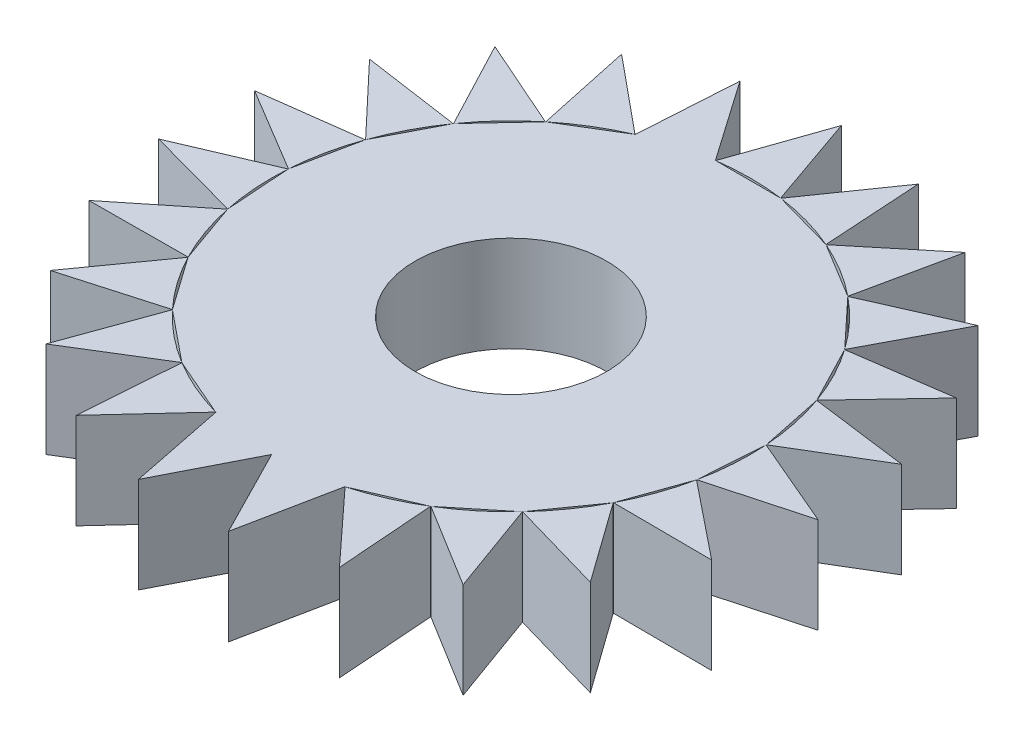
from build123d import *

# Parameters (mm, degrees)
BOSS_EXTRUDE1_DEPTH    = 2
SKETCH1_R              = 2
BOSS_EXTRUDE1_2_DEPTH  = 2
BOSS_EXTRUDE1_3_DEPTH  = 2
BOSS_EXTRUDE1_4_DEPTH  = 2
BOSS_EXTRUDE1_5_DEPTH  = 2
BOSS_EXTRUDE1_6_DEPTH  = 2
BOSS_EXTRUDE1_7_DEPTH  = 2
BOSS_EXTRUDE1_8_DEPTH  = 2
BOSS_EXTRUDE1_9_DEPTH  = 2
BOSS_EXTRUDE1_10_DEPTH = 2
BOSS_EXTRUDE1_11_DEPTH = 2
BOSS_EXTRUDE1_12_DEPTH = 2
BOSS_EXTRUDE1_13_DEPTH = 2
BOSS_EXTRUDE1_14_DEPTH = 2
BOSS_EXTRUDE1_15_DEPTH = 2
BOSS_EXTRUDE1_16_DEPTH = 2
BOSS_EXTRUDE1_17_DEPTH = 2
BOSS_EXTRUDE1_18_DEPTH = 2
BOSS_EXTRUDE1_19_DEPTH = 2
BOSS_EXTRUDE1_20_DEPTH = 2
BOSS_EXTRUDE1_21_DEPTH = 2


with BuildPart() as part:
    # Sketch1 → Boss-Extrude1 (new body)
    with BuildSketch(Plane(origin=(0, 0, 0), x_dir=(1, 0, 0), z_dir=(0, 1, 0))):
        with BuildLine():
            ThreePointArc((-0.678341052, 4.953771636), (0, 5), (0.678341052, 4.953771636))
            Line((0.678341052, 4.953771636), (0, 6.900057726))
            Line((0, 6.900057726), (-0.678341052, 4.953771636))
        make_face()
    extrude(amount=BOSS_EXTRUDE1_DEPTH)


with BuildPart() as body_2:
    # Sketch1 → Boss-Extrude1 2 (new body)
    with BuildSketch(Plane(origin=(0, 0, 0), x_dir=(1, 0, 0), z_dir=(0, 1, 0))):
        with BuildLine():
            ThreePointArc((0.683325267, 4.953086571), (0.680833245, 4.95342973), (0.678341052, 4.953771636))
            Line((0.678341052, 4.953771636), (-0.678341052, 4.953771636))
            ThreePointArc((-0.678341052, 4.953771636), (-0.680833245, 4.95342973), (-0.683325267, 4.953086571))
            Line((-0.683325267, 4.953086571), (-1.861613295, 6.644184868))
            Line((-1.861613295, 6.644184868), (-1.989697918, 4.58705812))
            ThreePointArc((-1.989697918, 4.58705812), (-1.992005449, 4.586056508), (-1.994312476, 4.585053734))
            Line((-1.994312476, 4.585053734), (-3.153487992, 3.880143488))
            ThreePointArc((-3.153487992, 3.880143488), (-3.155439722, 3.878556454), (-3.157390653, 3.876968437))
            Line((-3.157390653, 3.876968437), (-4.083398287, 2.885456364))
            ThreePointArc((-4.083398287, 2.885456364), (-4.084849465, 2.883401611), (-4.086299609, 2.881346127))
            Line((-4.086299609, 2.881346127), (-4.710461612, 1.676768141))
            ThreePointArc((-4.710461612, 1.676768141), (-4.711304611, 1.674398061), (-4.712146416, 1.672027556))
            Line((-4.712146416, 1.672027556), (-4.988171548, 0.343721697))
            ThreePointArc((-4.988171548, 0.343721697), (-4.988343846, 0.341212067), (-4.988514881, 0.338702351))
            Line((-4.988514881, 0.338702351), (-4.89593162, -1.014817014))
            ThreePointArc((-4.89593162, -1.014817014), (-4.895420438, -1.017280065), (-4.894908018, -1.019742859))
            Line((-4.894908018, -1.019742859), (-4.440582841, -2.298091389))
            ThreePointArc((-4.440582841, -2.298091389), (-4.439426092, -2.300325189), (-4.438268219, -2.302558406))
            Line((-4.438268219, -2.302558406), (-3.655896347, -3.410926839))
            ThreePointArc((-3.655896347, -3.410926839), (-3.654179821, -3.412765716), (-3.652462371, -3.414603729))
            Line((-3.652462371, -3.414603729), (-2.600068745, -4.270789449))
            ThreePointArc((-2.600068745, -4.270789449), (-2.59791975, -4.272097023), (-2.595770098, -4.273403515))
            Line((-2.595770098, -4.273403515), (-1.351405939, -4.813907144))
            ThreePointArc((-1.351405939, -4.813907144), (-1.348983856, -4.814586437), (-1.346561431, -4.815264511))
            Line((-1.346561431, -4.815264511), (-0.939557739, -6.835790216))
            Line((-0.939557739, -6.835790216), (-0.002515537, -4.999999367))
            ThreePointArc((-0.002515537, -4.999999367), (0, -5), (0.002515537, -4.999999367))
            Line((0.002515537, -4.999999367), (0.939557739, -6.835790216))
            Line((0.939557739, -6.835790216), (1.346561431, -4.815264511))
            ThreePointArc((1.346561431, -4.815264511), (1.348983856, -4.814586437), (1.351405939, -4.813907144))
            Line((1.351405939, -4.813907144), (2.595770098, -4.273403515))
            ThreePointArc((2.595770098, -4.273403515), (2.59791975, -4.272097023), (2.600068745, -4.270789449))
            Line((2.600068745, -4.270789449), (3.652462371, -3.414603729))
            ThreePointArc((3.652462371, -3.414603729), (3.654179821, -3.412765716), (3.655896347, -3.410926839))
            Line((3.655896347, -3.410926839), (4.438268219, -2.302558406))
            ThreePointArc((4.438268219, -2.302558406), (4.439426092, -2.300325189), (4.440582841, -2.298091389))
            Line((4.440582841, -2.298091389), (4.894908018, -1.019742859))
            ThreePointArc((4.894908018, -1.019742859), (4.895420438, -1.017280065), (4.89593162, -1.014817014))
            Line((4.89593162, -1.014817014), (4.988514881, 0.338702351))
            ThreePointArc((4.988514881, 0.338702351), (4.988343846, 0.341212067), (4.988171548, 0.343721697))
            Line((4.988171548, 0.343721697), (4.712146416, 1.672027556))
            ThreePointArc((4.712146416, 1.672027556), (4.711304611, 1.674398061), (4.710461612, 1.676768141))
            Line((4.710461612, 1.676768141), (4.086299609, 2.881346127))
            ThreePointArc((4.086299609, 2.881346127), (4.084849465, 2.883401611), (4.083398287, 2.885456364))
            Line((4.083398287, 2.885456364), (3.157390653, 3.876968437))
            ThreePointArc((3.157390653, 3.876968437), (3.155439722, 3.878556454), (3.153487992, 3.880143488))
            Line((3.153487992, 3.880143488), (1.994312476, 4.585053734))
            ThreePointArc((1.994312476, 4.585053734), (1.992005449, 4.586056508), (1.989697918, 4.58705812))
            Line((1.989697918, 4.58705812), (0.683325267, 4.953086571))
        make_face()
        Circle(SKETCH1_R, mode=Mode.SUBTRACT)
    extrude(amount=BOSS_EXTRUDE1_2_DEPTH)


with BuildPart() as body_3:
    # Sketch1 → Boss-Extrude1 3 (new body)
    with BuildSketch(Plane(origin=(0, 0, 0), x_dir=(1, 0, 0), z_dir=(0, 1, 0))):
        with BuildLine():
            Line((1.861613295, 6.644184868), (0.683325267, 4.953086571))
            ThreePointArc((0.683325267, 4.953086571), (1.348983856, 4.814586437), (1.989697918, 4.58705812))
            Line((1.989697918, 4.58705812), (1.861613295, 6.644184868))
        make_face()
    extrude(amount=BOSS_EXTRUDE1_3_DEPTH)


with BuildPart() as body_4:
    # Sketch1 → Boss-Extrude1 4 (new body)
    with BuildSketch(Plane(origin=(0, 0, 0), x_dir=(1, 0, 0), z_dir=(0, 1, 0))):
        with BuildLine():
            Line((3.585159249, 5.895543213), (1.994312476, 4.585053734))
            ThreePointArc((1.994312476, 4.585053734), (2.59791975, 4.272097023), (3.153487992, 3.880143488))
            Line((3.153487992, 3.880143488), (3.585159249, 5.895543213))
        make_face()
    extrude(amount=BOSS_EXTRUDE1_4_DEPTH)


with BuildPart() as body_5:
    # Sketch1 → Boss-Extrude1 5 (new body)
    with BuildSketch(Plane(origin=(0, 0, 0), x_dir=(1, 0, 0), z_dir=(0, 1, 0))):
        with BuildLine():
            ThreePointArc((-3.153487992, 3.880143488), (-2.59791975, 4.272097023), (-1.994312476, 4.585053734))
            Line((-1.994312476, 4.585053734), (-3.585159249, 5.895543213))
            Line((-3.585159249, 5.895543213), (-3.153487992, 3.880143488))
        make_face()
    extrude(amount=BOSS_EXTRUDE1_5_DEPTH)


with BuildPart() as body_6:
    # Sketch1 → Boss-Extrude1 6 (new body)
    with BuildSketch(Plane(origin=(0, 0, 0), x_dir=(1, 0, 0), z_dir=(0, 1, 0))):
        with BuildLine():
            Line((5.042810342, 4.709656089), (3.157390653, 3.876968437))
            ThreePointArc((3.157390653, 3.876968437), (3.654179821, 3.412765716), (4.083398287, 2.885456364))
            Line((4.083398287, 2.885456364), (5.042810342, 4.709656089))
        make_face()
    extrude(amount=BOSS_EXTRUDE1_6_DEPTH)


with BuildPart() as body_7:
    # Sketch1 → Boss-Extrude1 7 (new body)
    with BuildSketch(Plane(origin=(0, 0, 0), x_dir=(1, 0, 0), z_dir=(0, 1, 0))):
        with BuildLine():
            ThreePointArc((-4.083398287, 2.885456364), (-3.654179821, 3.412765716), (-3.157390653, 3.876968437))
            Line((-3.157390653, 3.876968437), (-5.042810342, 4.709656089))
            Line((-5.042810342, 4.709656089), (-4.083398287, 2.885456364))
        make_face()
    extrude(amount=BOSS_EXTRUDE1_7_DEPTH)


with BuildPart() as body_8:
    # Sketch1 → Boss-Extrude1 8 (new body)
    with BuildSketch(Plane(origin=(0, 0, 0), x_dir=(1, 0, 0), z_dir=(0, 1, 0))):
        with BuildLine():
            Line((6.126459261, 3.174475318), (4.086299609, 2.881346127))
            ThreePointArc((4.086299609, 2.881346127), (4.439426092, 2.300325189), (4.710461612, 1.676768141))
            Line((4.710461612, 1.676768141), (6.126459261, 3.174475318))
        make_face()
    extrude(amount=BOSS_EXTRUDE1_8_DEPTH)


with BuildPart() as body_9:
    # Sketch1 → Boss-Extrude1 9 (new body)
    with BuildSketch(Plane(origin=(0, 0, 0), x_dir=(1, 0, 0), z_dir=(0, 1, 0))):
        with BuildLine():
            ThreePointArc((-4.710461612, 1.676768141), (-4.439426092, 2.300325189), (-4.086299609, 2.881346127))
            Line((-4.086299609, 2.881346127), (-6.126459261, 3.174475318))
            Line((-6.126459261, 3.174475318), (-4.710461612, 1.676768141))
        make_face()
    extrude(amount=BOSS_EXTRUDE1_9_DEPTH)


with BuildPart() as body_10:
    # Sketch1 → Boss-Extrude1 10 (new body)
    with BuildSketch(Plane(origin=(0, 0, 0), x_dir=(1, 0, 0), z_dir=(0, 1, 0))):
        with BuildLine():
            Line((6.755736723, 1.403858235), (4.712146416, 1.672027556))
            ThreePointArc((4.712146416, 1.672027556), (4.895420438, 1.017280065), (4.988171548, 0.343721697))
            Line((4.988171548, 0.343721697), (6.755736723, 1.403858235))
        make_face()
    extrude(amount=BOSS_EXTRUDE1_10_DEPTH)


with BuildPart() as body_11:
    # Sketch1 → Boss-Extrude1 11 (new body)
    with BuildSketch(Plane(origin=(0, 0, 0), x_dir=(1, 0, 0), z_dir=(0, 1, 0))):
        with BuildLine():
            ThreePointArc((-4.988171548, 0.343721697), (-4.895420438, 1.017280065), (-4.712146416, 1.672027556))
            Line((-4.712146416, 1.672027556), (-6.755736723, 1.403858235))
            Line((-6.755736723, 1.403858235), (-4.988171548, 0.343721697))
        make_face()
    extrude(amount=BOSS_EXTRUDE1_11_DEPTH)


with BuildPart() as body_12:
    # Sketch1 → Boss-Extrude1 12 (new body)
    with BuildSketch(Plane(origin=(0, 0, 0), x_dir=(1, 0, 0), z_dir=(0, 1, 0))):
        with BuildLine():
            Line((6.883972099, -0.470876592), (4.988514881, 0.338702351))
            ThreePointArc((4.988514881, 0.338702351), (4.988343846, -0.341212067), (4.89593162, -1.014817014))
            Line((4.89593162, -1.014817014), (6.883972099, -0.470876592))
        make_face()
    extrude(amount=BOSS_EXTRUDE1_12_DEPTH)


with BuildPart() as body_13:
    # Sketch1 → Boss-Extrude1 13 (new body)
    with BuildSketch(Plane(origin=(0, 0, 0), x_dir=(1, 0, 0), z_dir=(0, 1, 0))):
        with BuildLine():
            ThreePointArc((-4.89593162, -1.014817014), (-4.988343846, -0.341212067), (-4.988514881, 0.338702351))
            Line((-4.988514881, 0.338702351), (-6.883972099, -0.470876592))
            Line((-6.883972099, -0.470876592), (-4.89593162, -1.014817014))
        make_face()
    extrude(amount=BOSS_EXTRUDE1_13_DEPTH)


with BuildPart() as body_14:
    # Sketch1 → Boss-Extrude1 14 (new body)
    with BuildSketch(Plane(origin=(0, 0, 0), x_dir=(1, 0, 0), z_dir=(0, 1, 0))):
        with BuildLine():
            Line((6.501654755, -2.310688655), (4.894908018, -1.019742859))
            ThreePointArc((4.894908018, -1.019742859), (4.711304611, -1.674398061), (4.440582841, -2.298091389))
            Line((4.440582841, -2.298091389), (6.501654755, -2.310688655))
        make_face()
    extrude(amount=BOSS_EXTRUDE1_14_DEPTH)


with BuildPart() as body_15:
    # Sketch1 → Boss-Extrude1 15 (new body)
    with BuildSketch(Plane(origin=(0, 0, 0), x_dir=(1, 0, 0), z_dir=(0, 1, 0))):
        with BuildLine():
            ThreePointArc((-4.440582841, -2.298091389), (-4.711304611, -1.674398061), (-4.894908018, -1.019742859))
            Line((-4.894908018, -1.019742859), (-6.501654755, -2.310688655))
            Line((-6.501654755, -2.310688655), (-4.440582841, -2.298091389))
        make_face()
    extrude(amount=BOSS_EXTRUDE1_15_DEPTH)


with BuildPart() as body_16:
    # Sketch1 → Boss-Extrude1 16 (new body)
    with BuildSketch(Plane(origin=(0, 0, 0), x_dir=(1, 0, 0), z_dir=(0, 1, 0))):
        with BuildLine():
            Line((5.637139422, -3.979127512), (4.438268219, -2.302558406))
            ThreePointArc((4.438268219, -2.302558406), (4.084849465, -2.883401611), (3.655896347, -3.410926839))
            Line((3.655896347, -3.410926839), (5.637139422, -3.979127512))
        make_face()
    extrude(amount=BOSS_EXTRUDE1_16_DEPTH)


with BuildPart() as body_17:
    # Sketch1 → Boss-Extrude1 17 (new body)
    with BuildSketch(Plane(origin=(0, 0, 0), x_dir=(1, 0, 0), z_dir=(0, 1, 0))):
        with BuildLine():
            ThreePointArc((-3.655896347, -3.410926839), (-4.084849465, -2.883401611), (-4.438268219, -2.302558406))
            Line((-4.438268219, -2.302558406), (-5.637139422, -3.979127512))
            Line((-5.637139422, -3.979127512), (-3.655896347, -3.410926839))
        make_face()
    extrude(amount=BOSS_EXTRUDE1_17_DEPTH)


with BuildPart() as body_18:
    # Sketch1 → Boss-Extrude1 18 (new body)
    with BuildSketch(Plane(origin=(0, 0, 0), x_dir=(1, 0, 0), z_dir=(0, 1, 0))):
        with BuildLine():
            Line((4.354543246, -5.352452684), (3.652462371, -3.414603729))
            ThreePointArc((3.652462371, -3.414603729), (3.155439722, -3.878556454), (2.600068745, -4.270789449))
            Line((2.600068745, -4.270789449), (4.354543246, -5.352452684))
        make_face()
    extrude(amount=BOSS_EXTRUDE1_18_DEPTH)


with BuildPart() as body_19:
    # Sketch1 → Boss-Extrude1 19 (new body)
    with BuildSketch(Plane(origin=(0, 0, 0), x_dir=(1, 0, 0), z_dir=(0, 1, 0))):
        with BuildLine():
            ThreePointArc((-2.600068745, -4.270789449), (-3.155439722, -3.878556454), (-3.652462371, -3.414603729))
            Line((-3.652462371, -3.414603729), (-4.354543246, -5.352452684))
            Line((-4.354543246, -5.352452684), (-2.600068745, -4.270789449))
        make_face()
    extrude(amount=BOSS_EXTRUDE1_19_DEPTH)


with BuildPart() as body_20:
    # Sketch1 → Boss-Extrude1 20 (new body)
    with BuildSketch(Plane(origin=(0, 0, 0), x_dir=(1, 0, 0), z_dir=(0, 1, 0))):
        with BuildLine():
            Line((2.748990518, -6.328810927), (2.595770098, -4.273403515))
            ThreePointArc((2.595770098, -4.273403515), (1.992005449, -4.586056508), (1.351405939, -4.813907144))
            Line((1.351405939, -4.813907144), (2.748990518, -6.328810927))
        make_face()
    extrude(amount=BOSS_EXTRUDE1_20_DEPTH)


with BuildPart() as body_21:
    # Sketch1 → Boss-Extrude1 21 (new body)
    with BuildSketch(Plane(origin=(0, 0, 0), x_dir=(1, 0, 0), z_dir=(0, 1, 0))):
        with BuildLine():
            ThreePointArc((-1.351405939, -4.813907144), (-1.992005449, -4.586056508), (-2.595770098, -4.273403515))
            Line((-2.595770098, -4.273403515), (-2.748990518, -6.328810927))
            Line((-2.748990518, -6.328810927), (-1.351405939, -4.813907144))
        make_face()
    extrude(amount=BOSS_EXTRUDE1_21_DEPTH)


solid = Compound([part.part, body_2.part, body_3.part, body_4.part, body_5.part, body_6.part, body_7.part, body_8.part, body_9.part, body_10.part, body_11.part, body_12.part, body_13.part, body_14.part, body_15.part, body_16.part, body_17.part, body_18.part, body_19.part, body_20.part, body_21.part])
